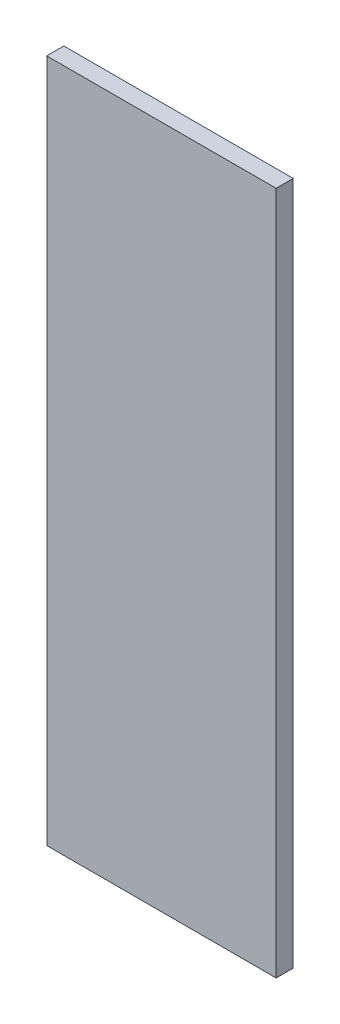
from build123d import *

# Parameters (mm, degrees)
SKETCH1_W           = 42.59709497
SKETCH1_H           = 127
BOSS_EXTRUDE1_DEPTH = 3.175


with BuildPart() as part:
    # Sketch1 → Boss-Extrude1 (new body)
    with BuildSketch(Plane.XY):
        Rectangle(SKETCH1_W, SKETCH1_H)
    extrude(amount=BOSS_EXTRUDE1_DEPTH)


solid = part.part
